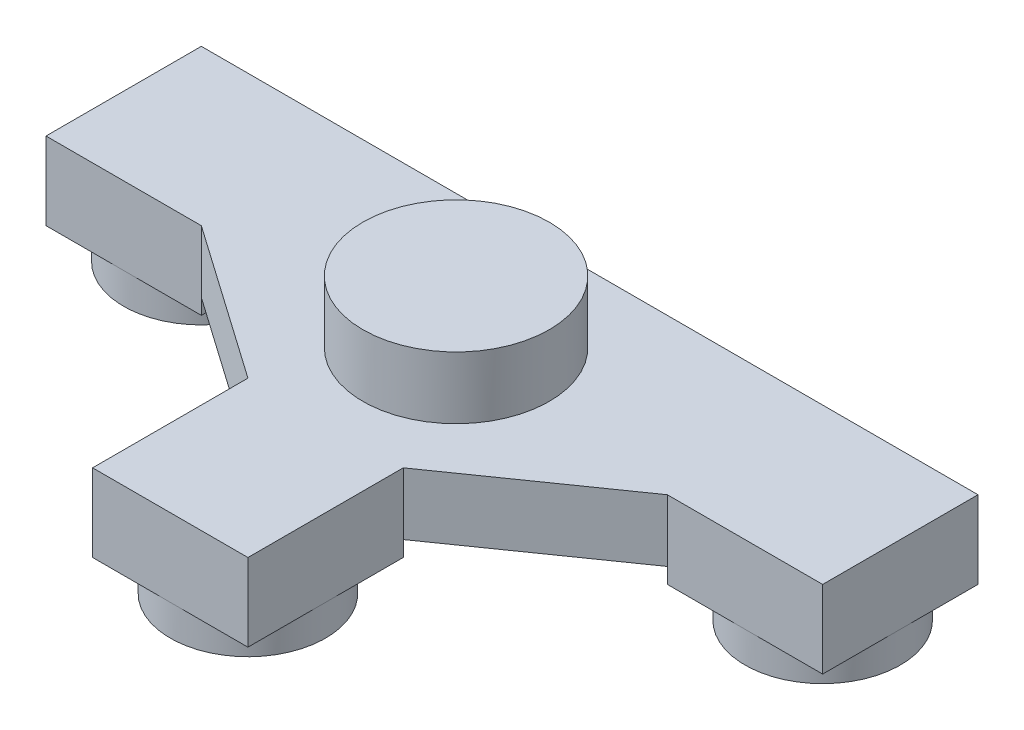
from build123d import *

# Parameters (mm, degrees)
EXTRUDE_1_DEPTH = 4
SKETCH_1_W      = 10
SKETCH_1_H      = 10
EXTRUDE_2_DEPTH = 1
SKETCH_5_R      = 6
EXTRUDE_3_DEPTH = 4
SKETCH_6_R      = 5
EXTRUDE_4_DEPTH = 2


with BuildPart() as part:
    # 草图2 → 凸台-拉伸1 (new body)
    with BuildSketch(Plane(origin=(0, 0, 0), x_dir=(1, 0, 0), z_dir=(0, 1, 0))):
        Polygon((-5, -22), (5, -22), (5, -12), (15, -5), (25, -5), (25, 5), (-25, 5), (-25, -5), (-15, -5), (-5, -12), align=None)
    extrude(amount=EXTRUDE_1_DEPTH)

    # 草图1 → 凸台-拉伸2 (add)
    with BuildSketch(Plane(origin=(0, 0, 0), x_dir=(1, 0, 0), z_dir=(0, 1, 0))):
        with Locations((-20, 0)):
            Rectangle(SKETCH_1_W, SKETCH_1_H)
        with Locations((20, 0)):
            Rectangle(SKETCH_1_W, SKETCH_1_H)
        with Locations((0, -17)):
            Rectangle(SKETCH_1_W, SKETCH_1_H)
    extrude(amount=-EXTRUDE_2_DEPTH)

    # 草图5 → 凸台-拉伸3 (add)
    with BuildSketch(Plane(origin=(0, 4, 0), x_dir=(1, 0, 0), z_dir=(0, 1, 0))):
        with Locations((0, -3.6)):
            Circle(SKETCH_5_R)
    extrude(amount=EXTRUDE_3_DEPTH)

    # 草图6 → 凸台-拉伸4 (add)
    with BuildSketch(Plane.XZ.offset(1)):
        with Locations((0, 17)):
            Circle(SKETCH_6_R)
        with Locations((20, 0)):
            Circle(SKETCH_6_R)
        with Locations((-20, 0)):
            Circle(SKETCH_6_R)
    extrude(amount=EXTRUDE_4_DEPTH)


solid = part.part
